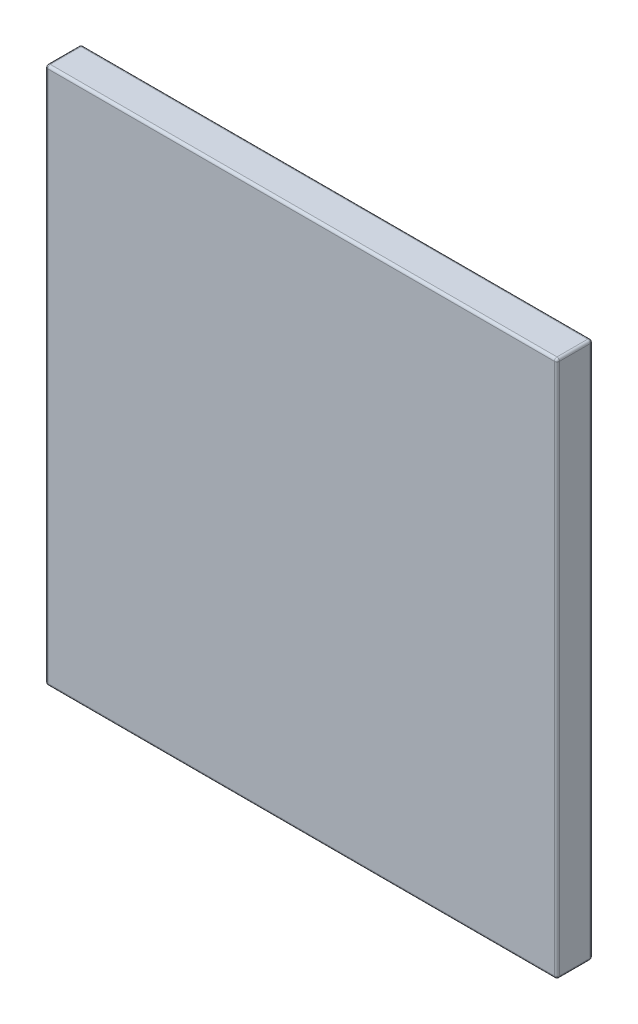
from build123d import *

# Parameters (mm, degrees)
SKETCH1_W           = 100
SKETCH1_H           = 105
BOSS_EXTRUDE1_DEPTH = 7
FILLET1_R           = 0.5


with BuildPart() as part:
    # Sketch1 → Boss-Extrude1 (new body)
    with BuildSketch(Plane.XY):
        with Locations((-54.134492072, -7.085363605)):
            Rectangle(SKETCH1_W, SKETCH1_H)
    extrude(amount=BOSS_EXTRUDE1_DEPTH)

    # Fillet1
    fillet1_edges = [part.edges().sort_by_distance(p)[0] for p in [
        (-104.134492072, -7.085363605, 7),
        (-54.134492072, -59.585363605, 7),
        (-4.134492072, -7.085363605, 7),
        (-54.134492072, -59.585363605, 0),
        (-104.134492072, -7.085363605, 0),
        (-54.134492072, 45.414636395, 0),
        (-4.134492072, -7.085363605, 0),
        (-54.134492072, 45.414636395, 7),
        (-4.134492072, -59.585363605, 3.5),
        (-104.134492072, -59.585363605, 3.5),
        (-104.134492072, 45.414636395, 3.5),
        (-4.134492072, 45.414636395, 3.5),
    ]]
    fillet(fillet1_edges, radius=FILLET1_R)


solid = part.part
